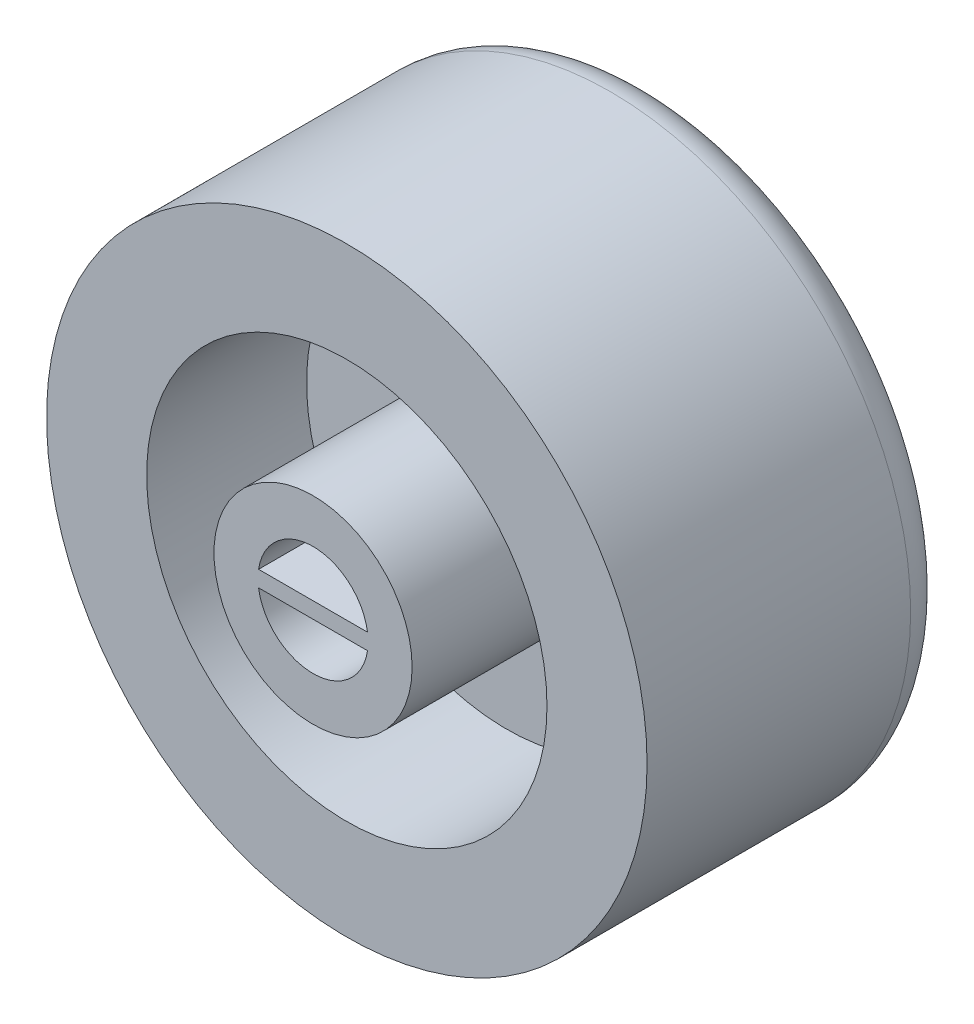
from build123d import *

# Parameters (mm, degrees)
FILLET1_R           = 2
SKETCH5_W           = 5.905041088
SKETCH5_H           = 0.8
BOSS_EXTRUDE4_DEPTH = 13


with BuildPart() as part:
    # Sketch1 → Revolve1 (revolve)
    with BuildSketch(Plane(origin=(0, 0, 0), x_dir=(1, 0, 0), z_dir=(0, 1, 0))):
        Polygon((2.75, 40.602114639), (2.75, 53.602114639), (0, 53.602114639), (0, 58.602114639), (15, 57.289784686), (15, 42.289784686), (10, 42.289784686), (10, 50.278222223), (4.95, 50.278222223), (4.95, 40.602114639), align=None)
    revolve(axis=Axis((0, 0, -53.602114639), (0, 0, -1)))

    # Fillet1
    fillet1_edges = [part.edges().sort_by_distance(p)[0] for p in [
        (-15, 0, -57.289784686),
    ]]
    fillet(fillet1_edges, radius=FILLET1_R)

    # Sketch5 → Boss-Extrude4 (add)
    with BuildSketch(Plane.XY.offset(-53.602114639)):
        with Locations((-0.048658074, 0)):
            Rectangle(SKETCH5_W, SKETCH5_H)
    extrude(amount=BOSS_EXTRUDE4_DEPTH)


solid = part.part
